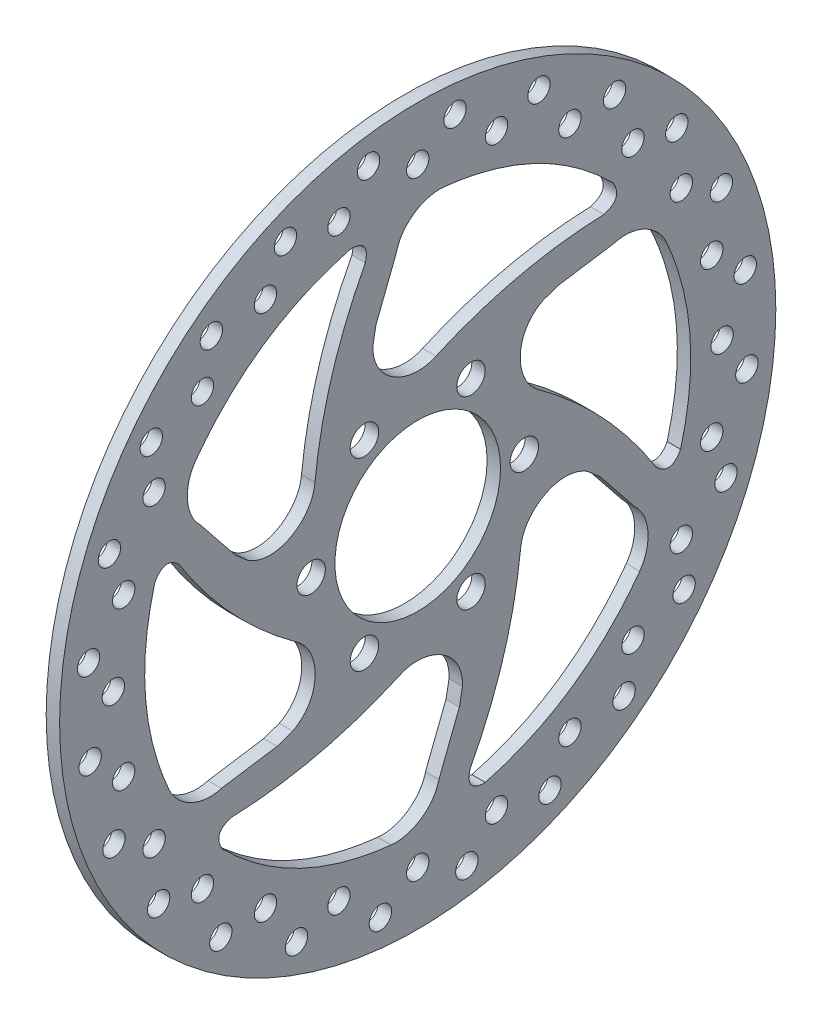
from build123d import *

# Parameters (mm, degrees)
SKETCH1_R           = 80
SKETCH1_R_2         = 2.5
SKETCH1_R_3         = 18.5
SKETCH1_R_4         = 3.175
BOSS_EXTRUDE1_DEPTH = 3


with BuildPart() as part:
    # Sketch1 → Boss-Extrude1 (new body)
    with BuildSketch(Plane(origin=(0, 0, 0), x_dir=(0, 0, -1), z_dir=(1, 0, 0))):
        Circle(SKETCH1_R)
        with Locations((0, 68)):
            Circle(SKETCH1_R_2, mode=Mode.SUBTRACT)
        with Locations((8.332202922, 73.529411765)):
            Circle(SKETCH1_R_2, mode=Mode.SUBTRACT)
        with Locations((17.599695067, 65.682956188)):
            Circle(SKETCH1_R_2, mode=Mode.SUBTRACT)
        with Locations((27.079102132, 68.867425011)):
            Circle(SKETCH1_R_2, mode=Mode.SUBTRACT)
        with Locations((34, 58.889727457)):
            Circle(SKETCH1_R_2, mode=Mode.SUBTRACT)
        with Locations((43.980605282, 59.512237052)):
            Circle(SKETCH1_R_2, mode=Mode.SUBTRACT)
        with Locations((48.083261121, 48.083261121)):
            Circle(SKETCH1_R_2, mode=Mode.SUBTRACT)
        with Locations((57.884902864, 46.101388487)):
            Circle(SKETCH1_R_2, mode=Mode.SUBTRACT)
        with Locations((58.889727457, 34)):
            Circle(SKETCH1_R_2, mode=Mode.SUBTRACT)
        with Locations((67.844439975, 29.548806482)):
            Circle(SKETCH1_R_2, mode=Mode.SUBTRACT)
        with Locations((65.682956188, 17.599695067)):
            Circle(SKETCH1_R_2, mode=Mode.SUBTRACT)
        with Locations((73.180490619, 10.982522147)):
            Circle(SKETCH1_R_2, mode=Mode.SUBTRACT)
        with Locations((68, 0)):
            Circle(SKETCH1_R_2, mode=Mode.SUBTRACT)
        with Locations((73.529411765, -8.332202922)):
            Circle(SKETCH1_R_2, mode=Mode.SUBTRACT)
        with Locations((65.682956188, -17.599695067)):
            Circle(SKETCH1_R_2, mode=Mode.SUBTRACT)
        with Locations((68.867425011, -27.079102132)):
            Circle(SKETCH1_R_2, mode=Mode.SUBTRACT)
        with Locations((58.889727457, -34)):
            Circle(SKETCH1_R_2, mode=Mode.SUBTRACT)
        with Locations((59.512237052, -43.980605282)):
            Circle(SKETCH1_R_2, mode=Mode.SUBTRACT)
        with Locations((48.083261121, -48.083261121)):
            Circle(SKETCH1_R_2, mode=Mode.SUBTRACT)
        with Locations((46.101388487, -57.884902864)):
            Circle(SKETCH1_R_2, mode=Mode.SUBTRACT)
        with Locations((34, -58.889727457)):
            Circle(SKETCH1_R_2, mode=Mode.SUBTRACT)
        with Locations((29.548806482, -67.844439975)):
            Circle(SKETCH1_R_2, mode=Mode.SUBTRACT)
        with Locations((17.599695067, -65.682956188)):
            Circle(SKETCH1_R_2, mode=Mode.SUBTRACT)
        with Locations((10.982522147, -73.180490619)):
            Circle(SKETCH1_R_2, mode=Mode.SUBTRACT)
        with Locations((0, -68)):
            Circle(SKETCH1_R_2, mode=Mode.SUBTRACT)
        with Locations((-8.332202922, -73.529411765)):
            Circle(SKETCH1_R_2, mode=Mode.SUBTRACT)
        with Locations((-17.599695067, -65.682956188)):
            Circle(SKETCH1_R_2, mode=Mode.SUBTRACT)
        with Locations((-27.079102132, -68.867425011)):
            Circle(SKETCH1_R_2, mode=Mode.SUBTRACT)
        with Locations((-34, -58.889727457)):
            Circle(SKETCH1_R_2, mode=Mode.SUBTRACT)
        with Locations((-43.980605282, -59.512237052)):
            Circle(SKETCH1_R_2, mode=Mode.SUBTRACT)
        with Locations((-48.083261121, -48.083261121)):
            Circle(SKETCH1_R_2, mode=Mode.SUBTRACT)
        with Locations((-57.884902864, -46.101388487)):
            Circle(SKETCH1_R_2, mode=Mode.SUBTRACT)
        with Locations((-58.889727457, -34)):
            Circle(SKETCH1_R_2, mode=Mode.SUBTRACT)
        with Locations((-67.844439975, -29.548806482)):
            Circle(SKETCH1_R_2, mode=Mode.SUBTRACT)
        with Locations((-65.682956188, -17.599695067)):
            Circle(SKETCH1_R_2, mode=Mode.SUBTRACT)
        with Locations((-73.180490619, -10.982522147)):
            Circle(SKETCH1_R_2, mode=Mode.SUBTRACT)
        with Locations((-68, 0)):
            Circle(SKETCH1_R_2, mode=Mode.SUBTRACT)
        with Locations((-73.529411765, 8.332202922)):
            Circle(SKETCH1_R_2, mode=Mode.SUBTRACT)
        with Locations((-65.682956188, 17.599695067)):
            Circle(SKETCH1_R_2, mode=Mode.SUBTRACT)
        with Locations((-68.867425011, 27.079102132)):
            Circle(SKETCH1_R_2, mode=Mode.SUBTRACT)
        with Locations((-58.889727457, 34)):
            Circle(SKETCH1_R_2, mode=Mode.SUBTRACT)
        with Locations((-59.512237052, 43.980605282)):
            Circle(SKETCH1_R_2, mode=Mode.SUBTRACT)
        with Locations((-48.083261121, 48.083261121)):
            Circle(SKETCH1_R_2, mode=Mode.SUBTRACT)
        with Locations((-46.101388487, 57.884902864)):
            Circle(SKETCH1_R_2, mode=Mode.SUBTRACT)
        with Locations((-34, 58.889727457)):
            Circle(SKETCH1_R_2, mode=Mode.SUBTRACT)
        with Locations((-29.548806482, 67.844439975)):
            Circle(SKETCH1_R_2, mode=Mode.SUBTRACT)
        with Locations((-17.599695067, 65.682956188)):
            Circle(SKETCH1_R_2, mode=Mode.SUBTRACT)
        with Locations((-10.982522147, 73.180490619)):
            Circle(SKETCH1_R_2, mode=Mode.SUBTRACT)
        Circle(SKETCH1_R_3, mode=Mode.SUBTRACT)
        with Locations((-11.90625, 20.622229928)):
            Circle(SKETCH1_R_4, mode=Mode.SUBTRACT)
        with Locations((11.90625, 20.622229928)):
            Circle(SKETCH1_R_4, mode=Mode.SUBTRACT)
        with Locations((23.8125, 0)):
            Circle(SKETCH1_R_4, mode=Mode.SUBTRACT)
        with Locations((11.90625, -20.622229928)):
            Circle(SKETCH1_R_4, mode=Mode.SUBTRACT)
        with Locations((-11.90625, -20.622229928)):
            Circle(SKETCH1_R_4, mode=Mode.SUBTRACT)
        with Locations((-23.8125, 0)):
            Circle(SKETCH1_R_4, mode=Mode.SUBTRACT)
        with BuildLine():
            Line((-9.315993321, 41.634868421), (-4.742741297, 53.355893883))
            add(Edge.make_bspline(
                [(-4.742741297, 53.355893883), (-3.617179994, 58.141088286), (1.364432068, 61.178922208), (5.953223317, 60.708806051)],
                knots=[0, 0, 0, 0, 1, 1, 1, 1], degree=3))
            add(Edge.make_bspline(
                [(5.953223317, 60.708806051), (27.994120627, 58.322754235), (43.642459298, 42.618490663)],
                knots=[0, 0, 0, 1, 1, 1], degree=2))
            add(Edge.make_bspline(
                [(41.595098769, 37.524132931), (45.940667236, 38.736285254), (43.642459298, 42.618490663)],
                knots=[0, 0, 0, 1, 1, 1], degree=2))
            add(Edge.make_bspline(
                [(4.081342093, 28.870780607), (21.997498313, 36.842130391), (41.595098769, 37.524132931)],
                knots=[0, 0, 0, 1, 1, 1], degree=2))
            add(Edge.make_bspline(
                [(4.081342093, 28.870780607), (-1.887276933, 26.023157642), (-10.304245695, 30.434997813), (-10, 38)],
                knots=[0, 0, 0, 0, 1, 1, 1, 1], degree=3))
            add(Edge.make_bspline(
                [(-10, 38), (-9.315993321, 41.634868421)],
                knots=[0, 0, 1, 1], degree=1))
        make_face(mode=Mode.SUBTRACT)
        with BuildLine():
            Line((31.398857075, 28.885321088), (43.836188896, 30.785281388))
            add(Edge.make_bspline(
                [(43.836188896, 30.785281388), (48.543069462, 32.203113908), (53.664716842, 29.407828271), (55.551979932, 25.198760399)],
                knots=[0, 0, 0, 0, 1, 1, 1, 1], degree=3))
            add(Edge.make_bspline(
                [(55.551979932, 25.198760399), (64.5060471, 4.917757498), (58.729925234, -16.486233105)],
                knots=[0, 0, 0, 1, 1, 1], degree=2))
            add(Edge.make_bspline(
                [(53.294401758, -17.260345741), (56.516940696, -20.417642266), (58.729925234, -16.486233105)],
                knots=[0, 0, 0, 1, 1, 1], degree=2))
            add(Edge.make_bspline(
                [(27.043500479, 10.90084437), (42.904970004, -0.629327163), (53.294401758, -17.260345741)],
                knots=[0, 0, 0, 1, 1, 1], degree=2))
            add(Edge.make_bspline(
                [(27.043500479, 10.90084437), (21.593077138, 14.646008589), (21.205358423, 24.141237446), (27.908965344, 27.660254038)],
                knots=[0, 0, 0, 0, 1, 1, 1, 1], degree=3))
            add(Edge.make_bspline(
                [(27.908965344, 27.660254038), (31.398857075, 28.885321088)],
                knots=[0, 0, 1, 1], degree=1))
        make_face(mode=Mode.SUBTRACT)
        with BuildLine():
            Line((40.714850396, -12.749547333), (48.578930193, -22.570612494))
            add(Edge.make_bspline(
                [(48.578930193, -22.570612494), (52.160249457, -25.937974378), (52.300284774, -31.771093936), (49.598756615, -35.510045652)],
                knots=[0, 0, 0, 0, 1, 1, 1, 1], degree=3))
            add(Edge.make_bspline(
                [(49.598756615, -35.510045652), (36.511926472, -53.404996737), (15.087465936, -59.104723768)],
                knots=[0, 0, 0, 1, 1, 1], degree=2))
            add(Edge.make_bspline(
                [(11.699302989, -54.784478672), (10.576273461, -59.15392752), (15.087465936, -59.104723768)],
                knots=[0, 0, 0, 1, 1, 1], degree=2))
            add(Edge.make_bspline(
                [(22.962158387, -17.969936237), (20.907471691, -37.471457554), (11.699302989, -54.784478672)],
                knots=[0, 0, 0, 1, 1, 1], degree=2))
            add(Edge.make_bspline(
                [(22.962158387, -17.969936237), (23.480354071, -11.377149053), (31.509604118, -6.293760367), (37.908965344, -10.339745962)],
                knots=[0, 0, 0, 0, 1, 1, 1, 1], degree=3))
            add(Edge.make_bspline(
                [(37.908965344, -10.339745962), (40.714850396, -12.749547333)],
                knots=[0, 0, 1, 1], degree=1))
        make_face(mode=Mode.SUBTRACT)
        with BuildLine():
            Line((9.315993321, -41.634868421), (4.742741297, -53.355893883))
            add(Edge.make_bspline(
                [(4.742741297, -53.355893883), (3.617179994, -58.141088286), (-1.364432068, -61.178922208), (-5.953223317, -60.708806051)],
                knots=[0, 0, 0, 0, 1, 1, 1, 1], degree=3))
            add(Edge.make_bspline(
                [(-5.953223317, -60.708806051), (-27.994120627, -58.322754235), (-43.642459298, -42.618490663)],
                knots=[0, 0, 0, 1, 1, 1], degree=2))
            add(Edge.make_bspline(
                [(-41.595098769, -37.524132931), (-45.940667236, -38.736285254), (-43.642459298, -42.618490663)],
                knots=[0, 0, 0, 1, 1, 1], degree=2))
            add(Edge.make_bspline(
                [(-4.081342093, -28.870780607), (-21.997498313, -36.842130391), (-41.595098769, -37.524132931)],
                knots=[0, 0, 0, 1, 1, 1], degree=2))
            add(Edge.make_bspline(
                [(-4.081342093, -28.870780607), (1.887276933, -26.023157642), (10.304245695, -30.434997813), (10, -38)],
                knots=[0, 0, 0, 0, 1, 1, 1, 1], degree=3))
            add(Edge.make_bspline(
                [(10, -38), (9.315993321, -41.634868421)],
                knots=[0, 0, 1, 1], degree=1))
        make_face(mode=Mode.SUBTRACT)
        with BuildLine():
            Line((-31.398857075, -28.885321088), (-43.836188896, -30.785281388))
            add(Edge.make_bspline(
                [(-43.836188896, -30.785281388), (-48.543069462, -32.203113908), (-53.664716842, -29.407828271), (-55.551979932, -25.198760399)],
                knots=[0, 0, 0, 0, 1, 1, 1, 1], degree=3))
            add(Edge.make_bspline(
                [(-55.551979932, -25.198760399), (-64.5060471, -4.917757498), (-58.729925234, 16.486233105)],
                knots=[0, 0, 0, 1, 1, 1], degree=2))
            add(Edge.make_bspline(
                [(-53.294401758, 17.260345741), (-56.516940696, 20.417642266), (-58.729925234, 16.486233105)],
                knots=[0, 0, 0, 1, 1, 1], degree=2))
            add(Edge.make_bspline(
                [(-27.043500479, -10.90084437), (-42.904970004, 0.629327163), (-53.294401758, 17.260345741)],
                knots=[0, 0, 0, 1, 1, 1], degree=2))
            add(Edge.make_bspline(
                [(-27.043500479, -10.90084437), (-21.593077138, -14.646008589), (-21.205358423, -24.141237446), (-27.908965344, -27.660254038)],
                knots=[0, 0, 0, 0, 1, 1, 1, 1], degree=3))
            add(Edge.make_bspline(
                [(-27.908965344, -27.660254038), (-31.398857075, -28.885321088)],
                knots=[0, 0, 1, 1], degree=1))
        make_face(mode=Mode.SUBTRACT)
        with BuildLine():
            Line((-40.714850396, 12.749547333), (-48.578930193, 22.570612494))
            add(Edge.make_bspline(
                [(-48.578930193, 22.570612494), (-52.160249457, 25.937974378), (-52.300284774, 31.771093936), (-49.598756615, 35.510045652)],
                knots=[0, 0, 0, 0, 1, 1, 1, 1], degree=3))
            add(Edge.make_bspline(
                [(-49.598756615, 35.510045652), (-36.511926472, 53.404996737), (-15.087465936, 59.104723768)],
                knots=[0, 0, 0, 1, 1, 1], degree=2))
            add(Edge.make_bspline(
                [(-11.699302989, 54.784478672), (-10.576273461, 59.15392752), (-15.087465936, 59.104723768)],
                knots=[0, 0, 0, 1, 1, 1], degree=2))
            add(Edge.make_bspline(
                [(-22.962158387, 17.969936237), (-20.907471691, 37.471457554), (-11.699302989, 54.784478672)],
                knots=[0, 0, 0, 1, 1, 1], degree=2))
            add(Edge.make_bspline(
                [(-22.962158387, 17.969936237), (-23.480354071, 11.377149053), (-31.509604118, 6.293760367), (-37.908965344, 10.339745962)],
                knots=[0, 0, 0, 0, 1, 1, 1, 1], degree=3))
            add(Edge.make_bspline(
                [(-37.908965344, 10.339745962), (-40.714850396, 12.749547333)],
                knots=[0, 0, 1, 1], degree=1))
        make_face(mode=Mode.SUBTRACT)
    extrude(amount=BOSS_EXTRUDE1_DEPTH)


solid = part.part
